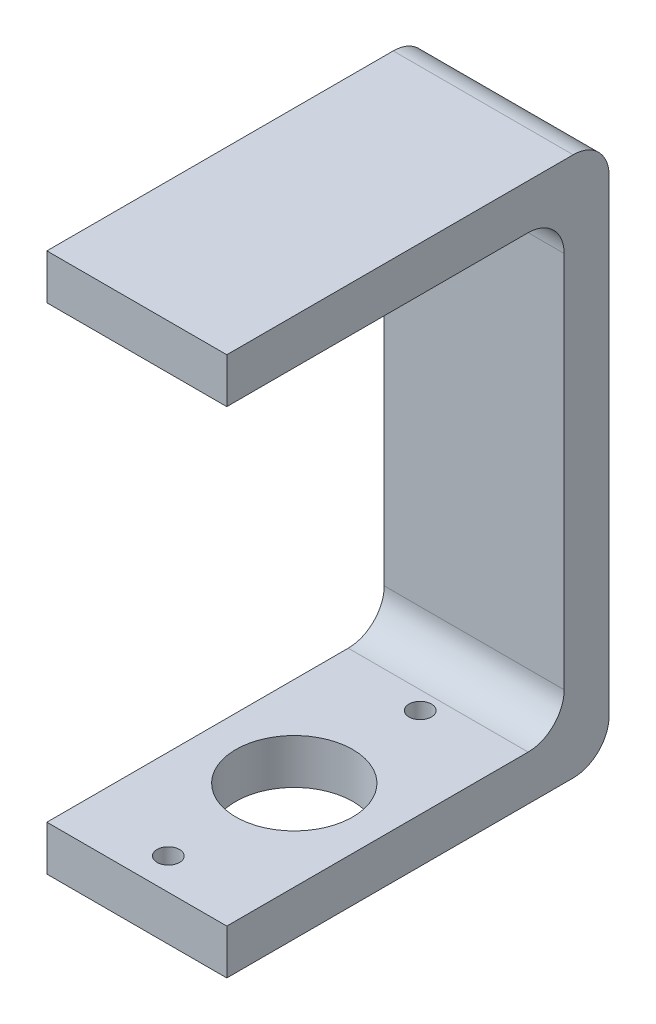
from build123d import *

# Parameters (mm, degrees)
EXTRUDE_1_DEPTH        = 40
CUT_EXTRUDE_1_REACH    = 122
SKETCH_5_R             = 13
HOLE_WIZARD_M6_1_D     = 5
HOLE_WIZARD_M6_1_DEPTH = 10


with BuildPart() as part:
    # 草图1 → 凸台-拉伸1 (new body)
    with BuildSketch(Plane(origin=(0, 0, 0), x_dir=(0, 0, -1), z_dir=(1, 0, 0))):
        with BuildLine():
            Line((0, 0), (77, 0))
            ThreePointArc((77, 0), (82.656854249, 2.343145751), (85, 8))
            Line((85, 8), (85, 112))
            ThreePointArc((85, 112), (82.656854249, 117.656854249), (77, 120))
            Line((77, 120), (0, 120))
            Line((0, 120), (0, 110))
            Line((0, 110), (67, 110))
            ThreePointArc((67, 110), (72.656854249, 107.656854249), (75, 102))
            Line((75, 102), (75, 18))
            ThreePointArc((75, 18), (72.656854249, 12.343145751), (67, 10))
            Line((67, 10), (0, 10))
            Line((0, 10), (0, 0))
        make_face()
    extrude(amount=EXTRUDE_1_DEPTH)

    # 草图5 → 切除-拉伸1 (cut, up to next)
    with BuildSketch(Plane.XZ, mode=Mode.PRIVATE) as cut_extrude_1_sk1:
        with Locations((20, -35)):
            Circle(SKETCH_5_R)
    cut_extrude_1_tool1 = extrude(cut_extrude_1_sk1.sketch, amount=-CUT_EXTRUDE_1_REACH, mode=Mode.PRIVATE) & part.part
    add(cut_extrude_1_tool1.solids().sort_by_distance((20, 0, -35))[0], mode=Mode.SUBTRACT)

    # M6 螺纹孔1
    with Locations(Plane(origin=(20, 0, -7), x_dir=(0, 0, -1), z_dir=(0, -1, 0))):
        with Locations((0, 0), (56, 0)):
            Hole(HOLE_WIZARD_M6_1_D / 2, depth=HOLE_WIZARD_M6_1_DEPTH)


solid = part.part
